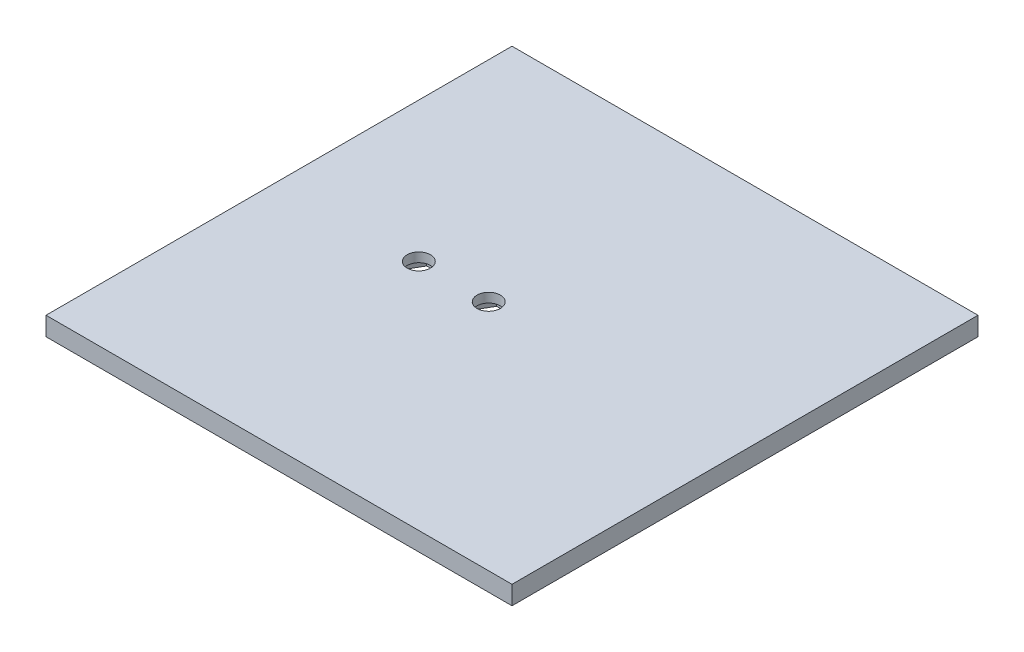
from build123d import *

# Parameters (mm, degrees)
SKETCH1_W           = 100
SKETCH1_H           = 100
BOSS_EXTRUDE1_DEPTH = 4
SKETCH3_R           = 2.5
CUT_EXTRUDE1_DEPTH  = 2
CUT_EXTRUDE2_DEPTH  = 2


with BuildPart() as part:
    # Sketch1 → Boss-Extrude1 (new body)
    with BuildSketch(Plane(origin=(0, 0, 0), x_dir=(1, 0, 0), z_dir=(0, 1, 0))):
        with Locations((15.12345679, -26.466049383)):
            Rectangle(SKETCH1_W, SKETCH1_H)
    extrude(amount=BOSS_EXTRUDE1_DEPTH)

    # Sketch3 → Cut-Extrude1 (cut)
    with BuildSketch(Plane(origin=(0, 4, 0), x_dir=(1, 0, 0), z_dir=(0, 1, 0))):
        with Locations((-4.87654321, -26.466049383)):
            Circle(SKETCH3_R)
        with Locations((10.12345679, -26.466049383)):
            Circle(SKETCH3_R)
    extrude(amount=-CUT_EXTRUDE1_DEPTH, mode=Mode.SUBTRACT)

    # Sketch5 → Cut-Extrude2 (cut)
    with BuildSketch(Plane.XZ):
        Polygon((-0.257741056, 26.466049383), (-2.567142133, 30.466049383), (-7.185944287, 30.466049383), (-9.495345363, 26.466049383), (-7.185944287, 22.466049383), (-2.567142133, 22.466049383), align=None)
        Polygon((14.742258944, 26.466049383), (12.432857867, 30.466049383), (7.814055713, 30.466049383), (5.504654637, 26.466049383), (7.814055713, 22.466049383), (12.432857867, 22.466049383), align=None)
    extrude(amount=-CUT_EXTRUDE2_DEPTH, mode=Mode.SUBTRACT)


solid = part.part
